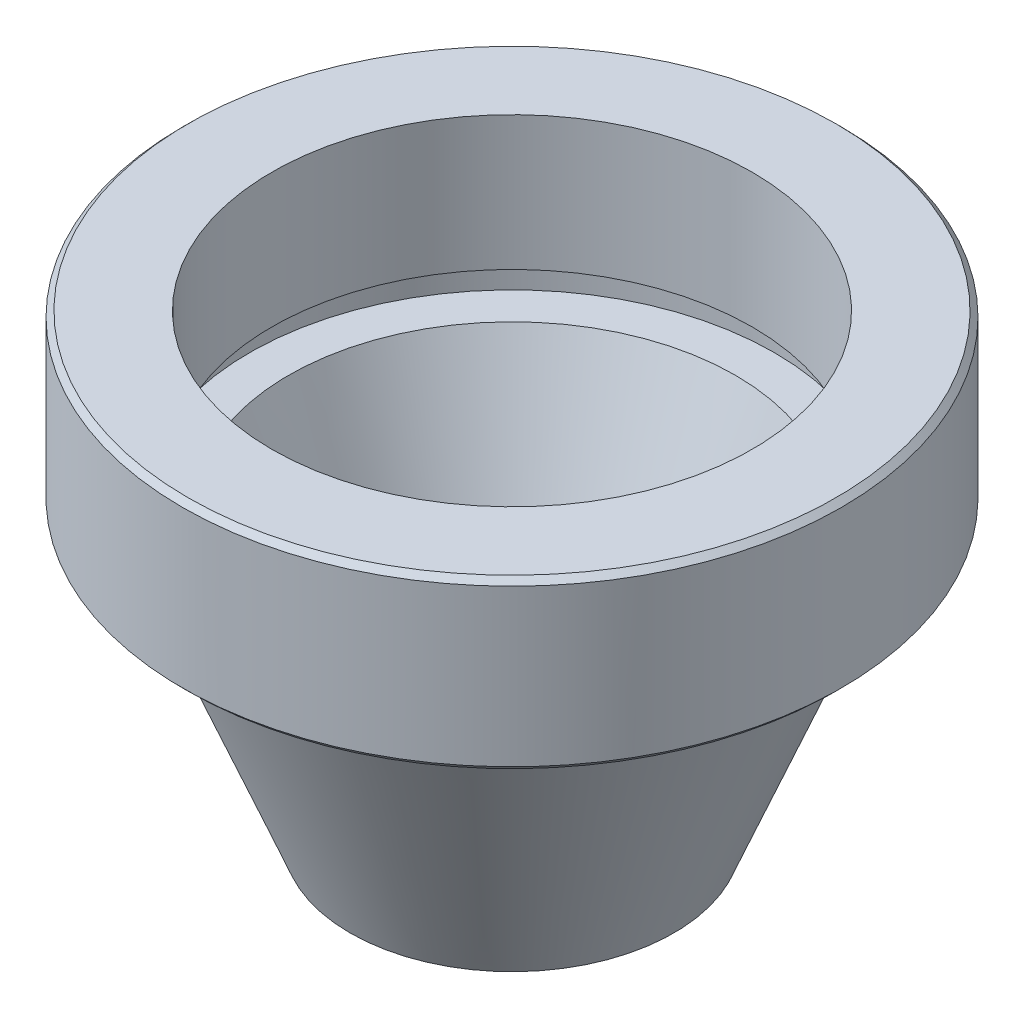
from build123d import *

# Parameters (mm, degrees)
CHANFRO1_SIZE = 0.5
FILETE1_R     = 3


with BuildPart() as part:
    # Esboço1 → Revolução1 (revolve)
    with BuildSketch(Plane(origin=(0, 0, 0), x_dir=(0, 0, -1), z_dir=(1, 0, 0))):
        Polygon((23.5, 20), (20, 20), (9.495318128, -6), (14.495318128, -6), (25, 20), (29.5, 20), (29.5, 35), (21.5, 35), (21.5, 23), (23.5, 23), align=None)
    revolve(axis=Axis((0, 0, 0), (0, 1, 0)))

    # Chanfro1
    chanfro1_edges = [part.edges().sort_by_distance(p)[0] for p in [
        (0, 35, 29.5),
        (0, 20, 29.5),
    ]]
    chamfer(chanfro1_edges, length=CHANFRO1_SIZE)

    # Filete1
    filete1_edges = [part.edges().sort_by_distance(p)[0] for p in [
        (0, 20, 25),
    ]]
    fillet(filete1_edges, radius=FILETE1_R)


solid = part.part
